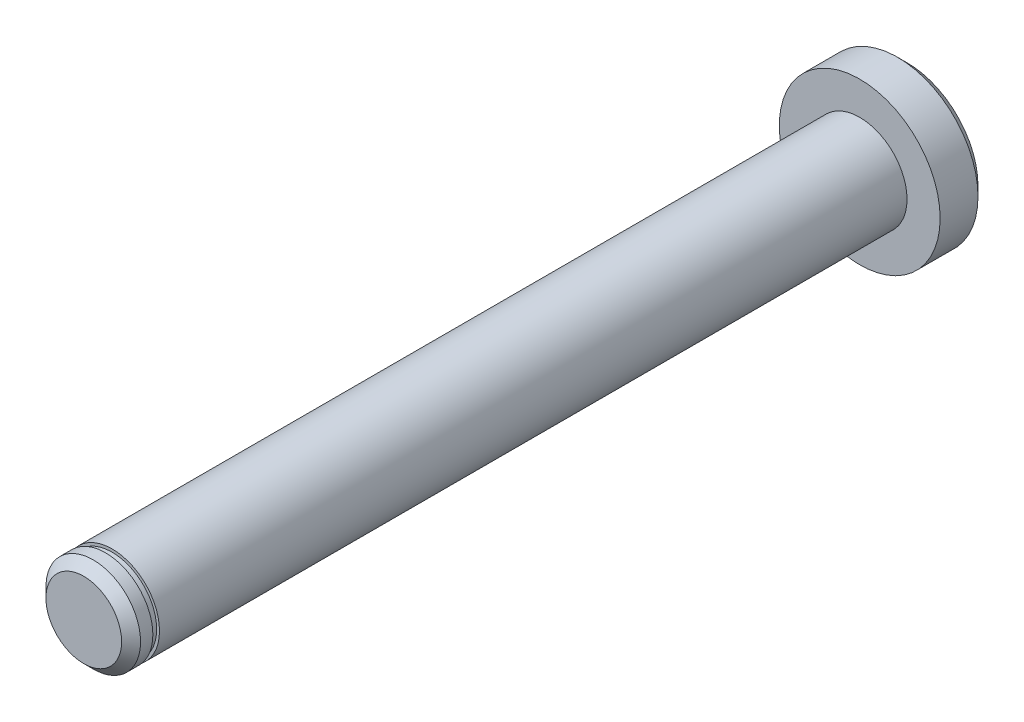
from build123d import *

# Parameters (mm, degrees)
SKETCH1_R               = 8.5
BOSS_EXTRUDE1_DEPTH     = 5
SKETCH2_R               = 5
BOSS_EXTRUDE2_DEPTH     = 82
CHAMFER1_SIZE           = 1
SKETCH3_R               = 14.7
SKETCH3_R_2             = 4.7
CUT_EXTRUDE_THIN1_DEPTH = 0.7


with BuildPart() as part:
    # Sketch1 → Boss-Extrude1 (new body)
    with BuildSketch(Plane.XY):
        Circle(SKETCH1_R)
    extrude(amount=BOSS_EXTRUDE1_DEPTH)

    # Sketch2 → Boss-Extrude2 (add)
    with BuildSketch(Plane.XY.offset(5)):
        Circle(SKETCH2_R)
    extrude(amount=BOSS_EXTRUDE2_DEPTH)

    # Chamfer1
    chamfer1_edges = [part.edges().sort_by_distance(p)[0] for p in [
        (-8.5, 0, 0),
        (-5, 0, 87),
    ]]
    chamfer(chamfer1_edges, length=CHAMFER1_SIZE)

    # Sketch3 → Cut-Extrude-Thin1 (cut)
    with BuildSketch(Plane.XY.offset(84)):
        Circle(SKETCH3_R)
        Circle(SKETCH3_R_2, mode=Mode.SUBTRACT)
    extrude(amount=CUT_EXTRUDE_THIN1_DEPTH, mode=Mode.SUBTRACT)


solid = part.part
